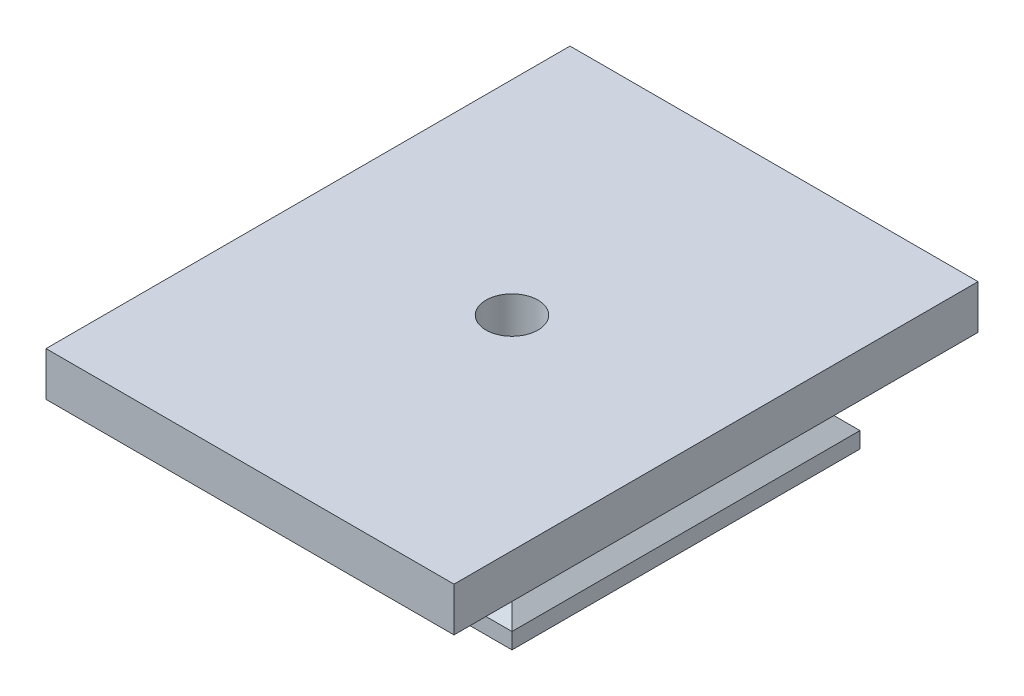
from build123d import *

# Parameters (mm, degrees)
SKETCH1_W           = 43.5
SKETCH1_H           = 43.5
BOSS_EXTRUDE1_DEPTH = 2
SKETCH2_W           = 43.5
SKETCH2_H           = 43.5
BOSS_EXTRUDE3_DEPTH = 7
CUT_EXTRUDE1_DEPTH  = 44.5
CUT_EXTRUDE2_DEPTH  = 44.5
SKETCH7_W           = 51
SKETCH7_H           = 65.5
BOSS_EXTRUDE4_DEPTH = 5.5
SKETCH8_R           = 3.25
CUT_EXTRUDE3_DEPTH  = 15.5
CUT_EXTRUDE4_DEPTH  = 6


with BuildPart() as part:
    # Sketch1 → Boss-Extrude1 (new body)
    with BuildSketch(Plane(origin=(0, 0, 0), x_dir=(1, 0, 0), z_dir=(0, 1, 0))):
        with Locations((-5.950471698, -3.385613208)):
            Rectangle(SKETCH1_W, SKETCH1_H)
    extrude(amount=BOSS_EXTRUDE1_DEPTH)


with BuildPart() as body_2:
    # Sketch2 → Boss-Extrude3 (new body)
    with BuildSketch(Plane(origin=(0, 2, 0), x_dir=(1, 0, 0), z_dir=(0, 1, 0))):
        with Locations((-5.950471698, -3.385613208)):
            Rectangle(SKETCH2_W, SKETCH2_H)
    extrude(amount=BOSS_EXTRUDE3_DEPTH)

    # Sketch5 → Cut-Extrude1 (cut, through all)
    with BuildSketch(Plane.XY.offset(25.135613208)):
        Polygon((15.799528302, 9), (8.799528302, 9), (15.799528302, 2), align=None)
        Polygon((-27.700471698, 9), (-27.700471698, 2), (-20.700471698, 9), align=None)
    extrude(amount=-CUT_EXTRUDE1_DEPTH, mode=Mode.SUBTRACT)

    # Sketch6 → Cut-Extrude2 (cut, through all)
    with BuildSketch(Plane(origin=(15.799528302, 0, 0), x_dir=(0, 0, -1), z_dir=(1, 0, 0))):
        Polygon((-25.135613208, 2), (-25.135613208, 9), (-18.135613208, 9), align=None)
        Polygon((18.364386792, 2), (18.364386792, 9), (11.364386792, 9), align=None)
    extrude(amount=-CUT_EXTRUDE2_DEPTH, mode=Mode.SUBTRACT)

    # Sketch7 → Boss-Extrude4 (add)
    with BuildSketch(Plane(origin=(0, 9, 0), x_dir=(1, 0, 0), z_dir=(0, 1, 0))):
        with Locations((-5.950471698, -3.385613208)):
            Rectangle(SKETCH7_W, SKETCH7_H)
    extrude(amount=BOSS_EXTRUDE4_DEPTH)


with BuildPart() as cut_extrude3_tool:
    # Sketch8 → Cut-Extrude3 (new body, through all)
    with BuildSketch(Plane.XZ):
        with Locations((-5.950471698, 3.385613208)):
            Circle(SKETCH8_R)
    extrude(amount=-CUT_EXTRUDE3_DEPTH)


with BuildPart() as part_1:
    add(part.part)

    # Cut-Extrude3: cut by cut_extrude3_tool
    add(cut_extrude3_tool.part, mode=Mode.SUBTRACT)


with BuildPart() as body_2_1:
    add(body_2.part)

    # Cut-Extrude3: cut by cut_extrude3_tool
    add(cut_extrude3_tool.part, mode=Mode.SUBTRACT)


with BuildPart() as cut_extrude4_tool:
    # Sketch9 → Cut-Extrude4 (new body)
    with BuildSketch(Plane.XZ):
        Polygon((-5.950471698, -3.253914888), (-0.200471698, 0.06584916), (-0.200471698, 6.705377255), (-5.950471698, 10.025141303), (-11.700471698, 6.705377255), (-11.700471698, 0.06584916), align=None)
    extrude(amount=-CUT_EXTRUDE4_DEPTH)


with BuildPart() as part_2:
    add(part_1.part)

    # Cut-Extrude4: cut by cut_extrude4_tool
    add(cut_extrude4_tool.part, mode=Mode.SUBTRACT)


with BuildPart() as body_2_2:
    add(body_2_1.part)

    # Cut-Extrude4: cut by cut_extrude4_tool
    add(cut_extrude4_tool.part, mode=Mode.SUBTRACT)


solid = Compound([part_2.part, body_2_2.part])
